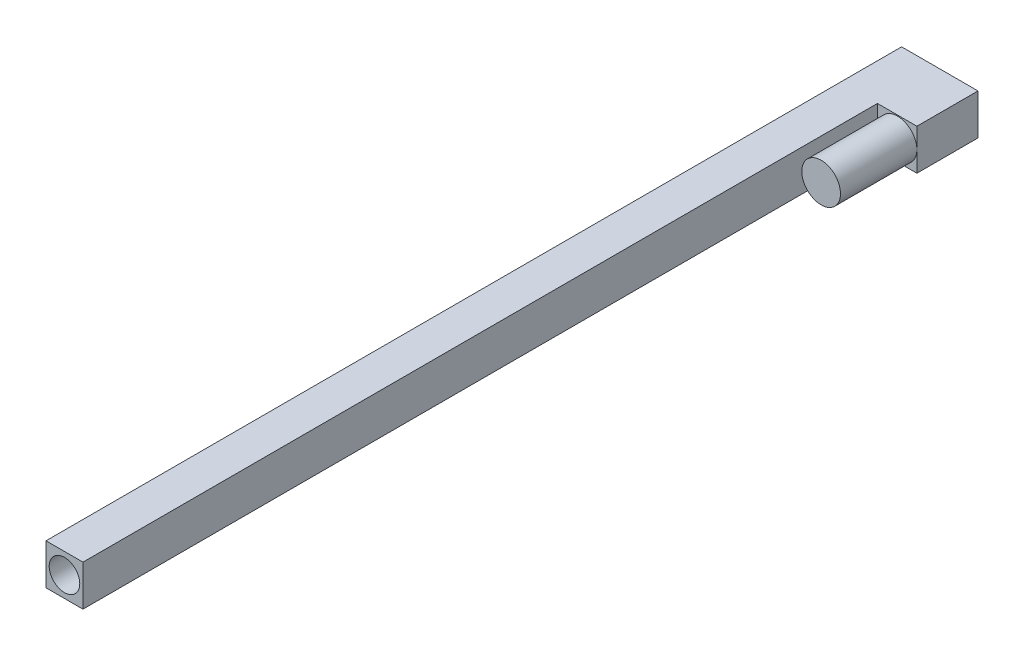
from build123d import *

# Parameters (mm, degrees)
SKETCH_1_W          = 75
SKETCH_1_H          = 40
EXTRUDE_1_DEPTH     = 60
SKETCH_2_R          = 19
EXTRUDE_2_DEPTH     = 75
SKETCH_3_W          = 36.2897677
SKETCH_3_H          = 40
EXTRUDE_3_DEPTH     = 780
SKETCH_7_R          = 15
CUT_EXTRUDE_1_DEPTH = 800


with BuildPart() as part:
    # 草圖1 → 填料-伸長1 (new body)
    with BuildSketch(Plane.XY):
        with Locations((-6.874209628, -1.106382979)):
            Rectangle(SKETCH_1_W, SKETCH_1_H)
    extrude(amount=EXTRUDE_1_DEPTH)

    # 草圖2 → 填料-伸長2 (add)
    with BuildSketch(Plane.XY.offset(60)):
        with Locations((11.625790372, -1.025700825)):
            Circle(SKETCH_2_R)
    extrude(amount=EXTRUDE_2_DEPTH)

    # 草圖3 → 填料-伸長3 (add)
    with BuildSketch(Plane.XY.offset(60)):
        with Locations((-26.229325778, -1.106382979)):
            Rectangle(SKETCH_3_W, SKETCH_3_H)
    extrude(amount=EXTRUDE_3_DEPTH)

    # 草圖7 → 除料-伸長1 (cut)
    with BuildSketch(Plane.XY.offset(840)):
        with Locations((-26.229325778, -1.106382979)):
            Circle(SKETCH_7_R)
    extrude(amount=-CUT_EXTRUDE_1_DEPTH, mode=Mode.SUBTRACT)


solid = part.part
